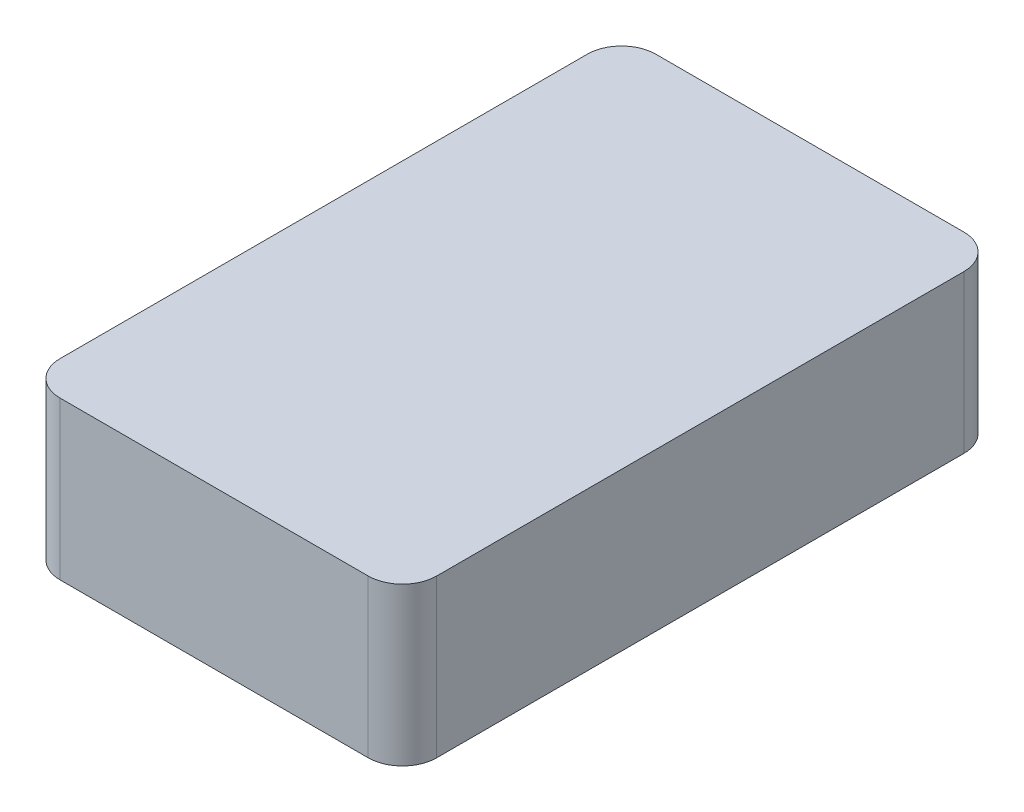
from build123d import *

# Parameters (mm, degrees)
BOSS_EXTRUDE1_DEPTH = 23


with BuildPart() as part:
    # Sketch1 → Boss-Extrude1 (new body)
    with BuildSketch(Plane(origin=(0, 0, 0), x_dir=(1, 0, 0), z_dir=(0, 1, 0))):
        with BuildLine():
            Line((-34.939931315, -25.784120919), (10.060068685, -25.784120919))
            ThreePointArc((10.060068685, -25.784120919), (13.595602591, -24.319654825), (15.060068685, -20.784120919))
            Line((15.060068685, -20.784120919), (15.060068685, 56.215879081))
            ThreePointArc((15.060068685, 56.215879081), (13.595602591, 59.751412987), (10.060068685, 61.215879081))
            Line((10.060068685, 61.215879081), (-34.939931315, 61.215879081))
            ThreePointArc((-34.939931315, 61.215879081), (-38.475465221, 59.751412987), (-39.939931315, 56.215879081))
            Line((-39.939931315, 56.215879081), (-39.939931315, -20.784120919))
            ThreePointArc((-39.939931315, -20.784120919), (-38.475465221, -24.319654825), (-34.939931315, -25.784120919))
        make_face()
    extrude(amount=BOSS_EXTRUDE1_DEPTH)


solid = part.part
